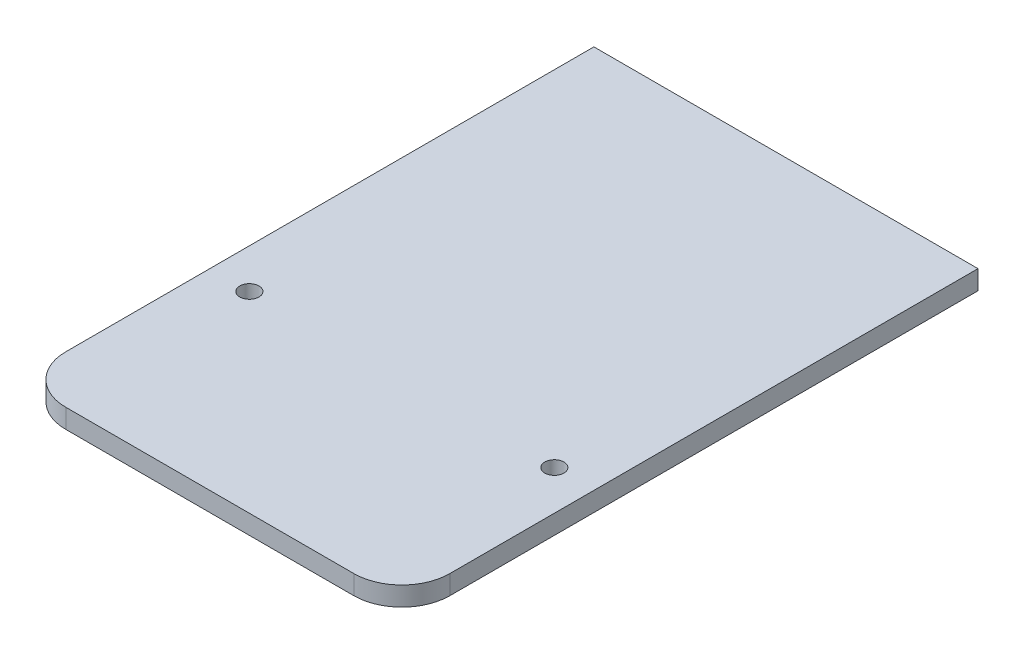
from build123d import *

# Parameters (mm, degrees)
BOSS_EXTRUDE1_DEPTH = 10
SKETCH2_R           = 5
CUT_EXTRUDE1_DEPTH  = 11


with BuildPart() as part:
    # Sketch1 → Boss-Extrude1 (new body)
    with BuildSketch(Plane(origin=(0, 0, 0), x_dir=(1, 0, 0), z_dir=(0, 1, 0))):
        with BuildLine():
            Line((-100, 150), (100, 150))
            Line((100, 150), (100, -125))
            ThreePointArc((100, -125), (92.67766953, -142.67766953), (75, -150))
            Line((75, -150), (-75, -150))
            ThreePointArc((-75, -150), (-92.67766953, -142.67766953), (-100, -125))
            Line((-100, -125), (-100, 150))
        make_face()
    extrude(amount=-BOSS_EXTRUDE1_DEPTH)

    # Sketch2 → Cut-Extrude1 (cut, through all)
    with BuildSketch(Plane(origin=(0, 0, 0), x_dir=(1, 0, 0), z_dir=(0, 1, 0))):
        with Locations((-79.4, -50)):
            Circle(SKETCH2_R)
        with Locations((79.4, -50)):
            Circle(SKETCH2_R)
    extrude(amount=-CUT_EXTRUDE1_DEPTH, mode=Mode.SUBTRACT)


solid = part.part
